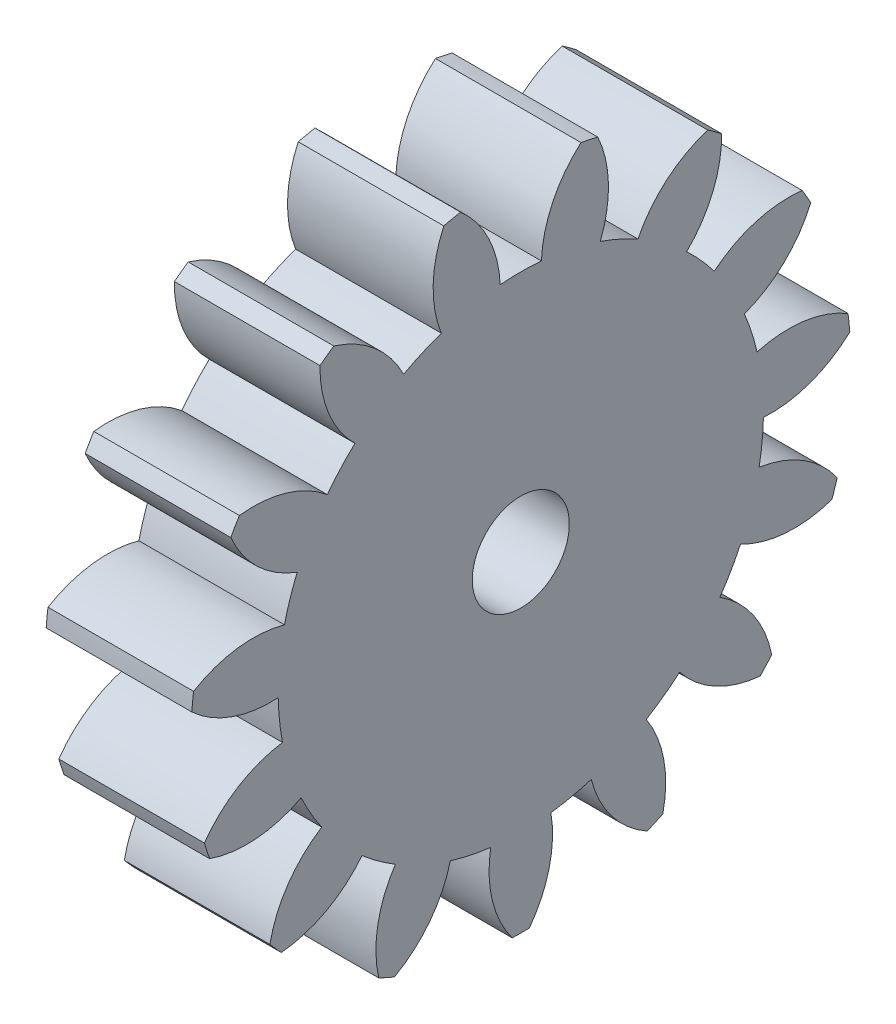
from build123d import *

# Parameters (mm, degrees)
BASPROSKE_W     = 19.05
BASPROSKE_H     = 43.18
TOOTHCUT_DEPTH  = 64.968174118
TEETHCUTS_COUNT = 15
TEETHCUTS_ANGLE = 336
BORSKE_R        = 6.35
BORE_DEPTH      = 50.8000508


with BuildPart() as part:
    # BasProSke → Base-Revolve (revolve)
    with BuildSketch(Plane(origin=(0, 0, 0), x_dir=(1, 0, 0), z_dir=(0, 1, 0)), mode=Mode.PRIVATE) as base_revolve_sk:
        with Locations((9.525, 21.59)):
            Rectangle(BASPROSKE_W, BASPROSKE_H)
    revolve(base_revolve_sk.sketch.rotate(Axis((-10, 0, 0), (1, 0, 0)), 180), axis=Axis((-10, 0, 0), (1, 0, 0)))

    # TooCutSke → ToothCut (cut, through all)
    with BuildSketch(Plane(origin=(0, 0, 0), x_dir=(0, 0, -1), z_dir=(1, 0, 0))):
        with BuildLine():
            ThreePointArc((2.696859547, 31.633981811), (0, 31.74873), (-2.696859547, 31.633981811))
            ThreePointArc((-2.696859547, 31.633981811), (-4.185540078, 37.590553983), (-7.903959541, 42.476275881))
            ThreePointArc((-7.903959541, 42.476275881), (0, 43.2054), (7.903959541, 42.476275881))
            ThreePointArc((7.903959541, 42.476275881), (4.185540078, 37.590553983), (2.696859547, 31.633981811))
        make_face()
    toothcut = extrude(amount=TOOTHCUT_DEPTH, mode=Mode.SUBTRACT)

    # TeethCuts: ToothCut ×15 about axis
    teethcuts_axis = Axis((-10, 0, 0), (1, 0, 0))
    for i in range(1, TEETHCUTS_COUNT):
        add(toothcut.rotate(teethcuts_axis, i * TEETHCUTS_ANGLE / (TEETHCUTS_COUNT - 1)), mode=Mode.SUBTRACT)

    # BorSke → Bore (cut, symmetric)
    with BuildSketch(Plane(origin=(0, 0, 0), x_dir=(0, 0, -1), z_dir=(1, 0, 0))):
        with Locations(Location((0, 0, 0), (0, 0, 180))):
            Circle(BORSKE_R)
    extrude(amount=BORE_DEPTH, both=True, mode=Mode.SUBTRACT)


solid = part.part
